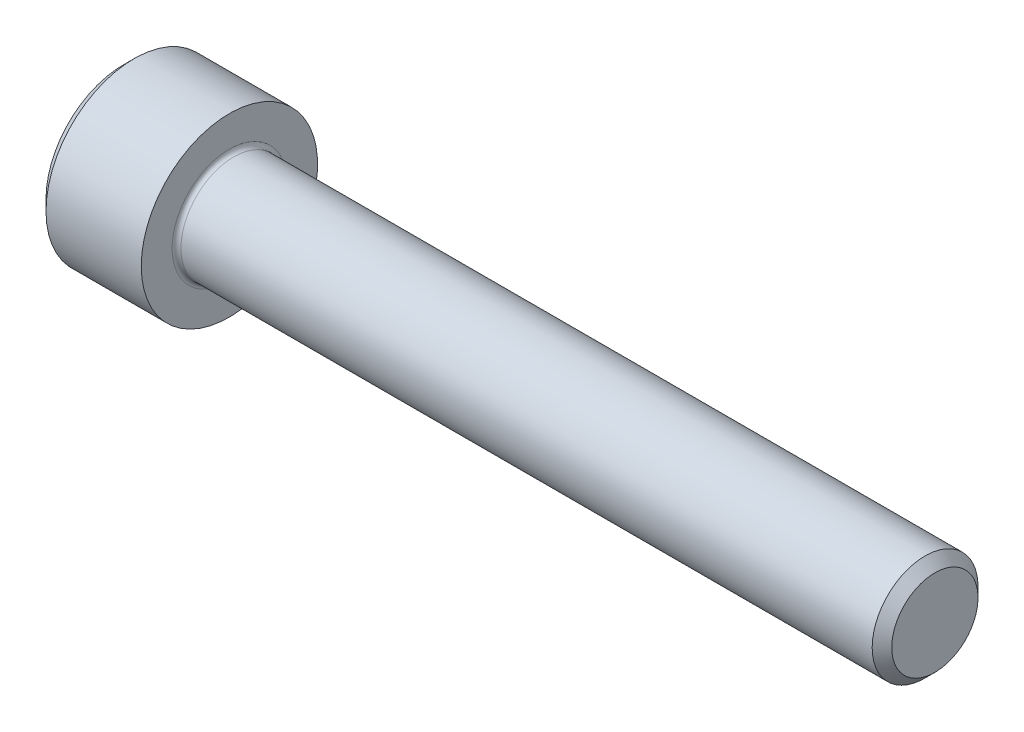
from build123d import *

# Parameters (mm, degrees)
FILLET1_R   = 0.25
HEX_2_DEPTH = 3


with BuildPart() as part:
    # BodySke → Base-Revolve (revolve)
    with BuildSketch(Plane.XY):
        Polygon((0, 0), (0, 4.4), (0.6, 5), (6, 5), (6, 3), (45.4455, 3), (46, 2.4455), (46, 0), align=None)
    revolve(axis=Axis((-31.75, 0, 0), (1, 0, 0)))

    # Fillet1
    fillet1_edges = [part.edges().sort_by_distance(p)[0] for p in [
        (6, -3, 0),
    ]]
    fillet(fillet1_edges, radius=FILLET1_R)

    # Sketch2 → Hex-PreBroach (revolve, cut)
    with BuildSketch(Plane.XY):
        Polygon((0, 2.542), (3, 2.542), (4.467624384, 0), (0, 0), align=None)
    revolve(axis=Axis((0, 0, 0), (1, 0, 0)), mode=Mode.SUBTRACT)

    # Sketch3 → Hex 2 (cut)
    with BuildSketch(Plane(origin=(0, 0, 0), x_dir=(0, 0.5, 0.866025404), z_dir=(-1, 0, 0))):
        Polygon((1.467624384, 2.542), (-1.467624384, 2.542), (-2.935248769, 0), (-1.467624384, -2.542), (1.467624384, -2.542), (2.935248769, 0), align=None)
    extrude(amount=-HEX_2_DEPTH, mode=Mode.SUBTRACT)


solid = part.part
